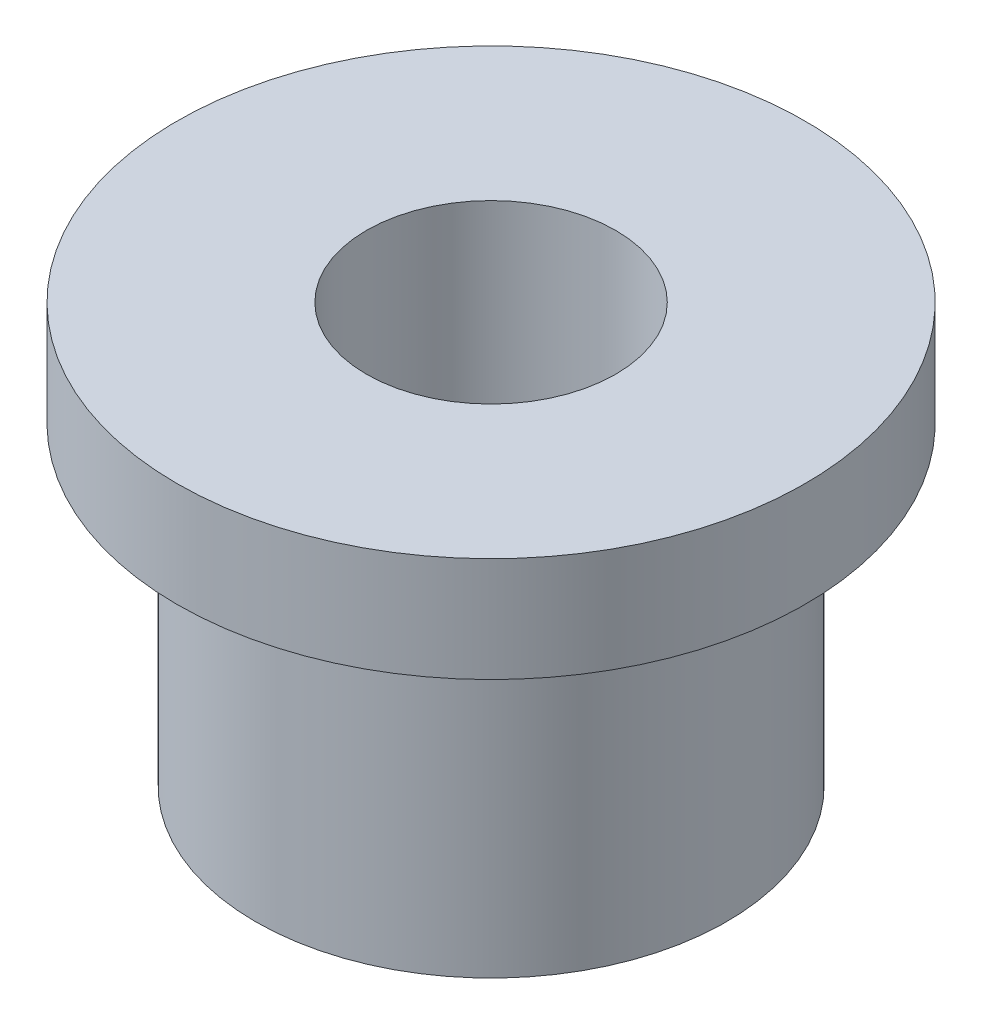
from build123d import *


with BuildPart() as part:
    # Esboço1 → Revolução1 (revolve)
    with BuildSketch(Plane.XY, mode=Mode.PRIVATE) as revolu_o1_sk:
        Polygon((4.7625, 8), (12, 8), (12, 4), (9, 4), (9, -8), (4.7625, -8), align=None)
    revolve(revolu_o1_sk.sketch.rotate(Axis((0, 8, 0), (0, -1, 0)), 90), axis=Axis((0, 8, 0), (0, -1, 0)))  # turned: the seam where the file's is


solid = part.part
